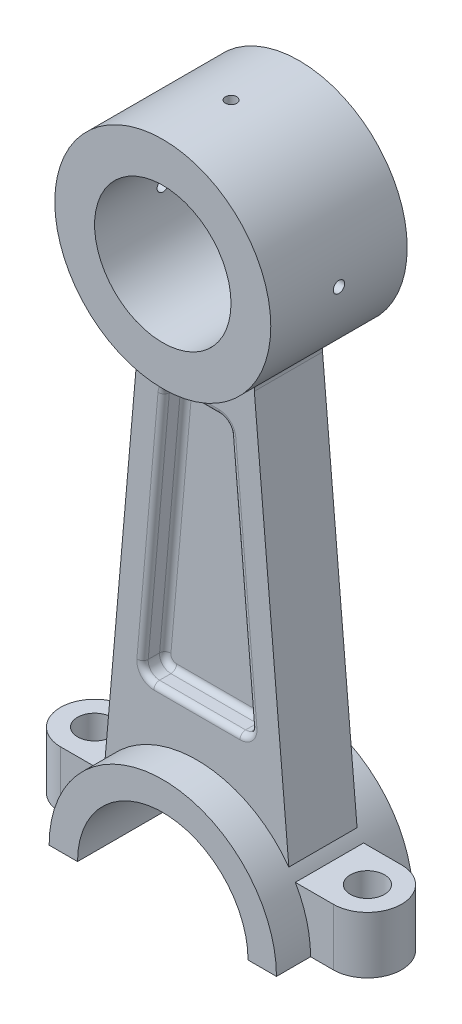
from build123d import *

# Parameters (mm, degrees)
Y_KSEKLIK_EKSTR_ZYON1_DEPTH = 12
Y_KSEKLIK_EKSTR_ZYON2_DEPTH = 6
IZIM1_4_R                   = 19
IZIM1_4_R_2                 = 12
Y_KSEKLIK_EKSTR_ZYON3_DEPTH = 12
IZIM1_5_W                   = 6
IZIM1_5_H                   = 10
Y_KSEKLIK_EKSTR_ZYON4_DEPTH = 6
KES_EKSTR_ZYON1_DEPTH       = 11
F_6_0_6_AP_DELIK1_D         = 6
KES_EKSTR_ZYON2_DEPTH       = 4
RADYUS1_R                   = 1
RADYUS2_R                   = 1
IZIM9_R                     = 1
KES_EKSTR_ZYON3_DEPTH       = 50
IZIM10_R                    = 1
KES_EKSTR_ZYON4_DEPTH       = 16
RADYUS3_R                   = 2


with BuildPart() as part:
    # Çizim1 → Yükseklik-Ekstrüzyon1 (new body, symmetric)
    with BuildSketch(Plane.XY):
        with BuildLine():
            Line((-20, 0), (-15, 0))
            ThreePointArc((-15, 0), (0, 15), (15, 0))
            Line((15, 0), (20, 0))
            ThreePointArc((20, 0), (0, 20), (-20, 0))
        make_face()
    extrude(amount=Y_KSEKLIK_EKSTR_ZYON1_DEPTH, both=True)

    # Çizim1<3> → Yükseklik-Ekstrüzyon2 (add, symmetric)
    with BuildSketch(Plane.XY):
        with BuildLine():
            Line((-10, 82.394505579), (-16.180060624, 11.756089409))
            ThreePointArc((-16.180060624, 11.756089409), (0, 20), (16.180060624, 11.756089409))
            Line((16.180060624, 11.756089409), (10, 82.394505579))
            ThreePointArc((10, 82.394505579), (0, 79.55), (-10, 82.394505579))
        make_face()
    extrude(amount=Y_KSEKLIK_EKSTR_ZYON2_DEPTH, both=True)

    # Çizim1<4> → Yükseklik-Ekstrüzyon3 (add, symmetric)
    with BuildSketch(Plane.XY):
        with Locations((0, 98.55)):
            Circle(IZIM1_4_R)
        with Locations((0, 98.55)):
            Circle(IZIM1_4_R_2, mode=Mode.SUBTRACT)
    extrude(amount=Y_KSEKLIK_EKSTR_ZYON3_DEPTH, both=True)

    # Çizim1<5> → Yükseklik-Ekstrüzyon4 (add, symmetric)
    with BuildSketch(Plane.XY):
        with Locations((-27, 5)):
            Rectangle(IZIM1_5_W, IZIM1_5_H)
        with BuildLine():
            Line((-24, 0), (-20, 0))
            ThreePointArc((-20, 0), (-19.318516526, 5.176380902), (-17.320508076, 10))
            Line((-17.320508076, 10), (-24, 10))
            Line((-24, 10), (-24, 0))
        make_face()
        with BuildLine():
            ThreePointArc((17.320508076, 10), (19.318516526, 5.176380902), (20, 0))
            Line((20, 0), (24, 0))
            Line((24, 0), (24, 10))
            Line((24, 10), (17.320508076, 10))
        make_face()
        with Locations((27, 5)):
            Rectangle(IZIM1_5_W, IZIM1_5_H)
    extrude(amount=Y_KSEKLIK_EKSTR_ZYON4_DEPTH, both=True)

    # Çizim2 → Kes-Ekstrüzyon1 (cut, through all)
    with BuildSketch(Plane(origin=(0, 10, 0), x_dir=(1, 0, 0), z_dir=(0, 1, 0))):
        with BuildLine():
            ThreePointArc((-30, 0), (-28.242640687, 4.242640687), (-24, 6))
            Line((-24, 6), (-30, 6))
            Line((-30, 6), (-30, 0))
        make_face()
        with BuildLine():
            Line((-30, -6), (-24, -6))
            ThreePointArc((-24, -6), (-28.242640687, -4.242640687), (-30, 0))
            Line((-30, 0), (-30, -6))
        make_face()
    kes_ekstr_zyon1 = extrude(amount=-KES_EKSTR_ZYON1_DEPTH, mode=Mode.SUBTRACT)

    # Ø6.0 (6) Çap Delik1 (through all)
    with Locations(Plane(origin=(0, 10, 0), x_dir=(1, 0, 0), z_dir=(0, 1, 0))):
        with Locations((-24, 0)):
            f_6_0_6_ap_delik1 = Hole(F_6_0_6_AP_DELIK1_D / 2)

    # Aynalama1: Ø6.0 (6) Çap Delik1 across plane
    add(f_6_0_6_ap_delik1.mirror(Plane(origin=(0, 0, 0), x_dir=(0, 0, 1), z_dir=(1, 0, 0))), mode=Mode.SUBTRACT)

    # Çizim8 → Kes-Ekstrüzyon2 (cut)
    with BuildSketch(Plane.XY.offset(6)):
        with BuildLine():
            Line((5.845451143, 72.512650075), (9.562487885, 30.026725708))
            ThreePointArc((9.562487885, 30.026725708), (9.044653162, 28.501233808), (7.570098489, 27.852414223))
            Line((7.570098489, 27.852414223), (-7.570098489, 27.852414223))
            ThreePointArc((-7.570098489, 27.852414223), (-9.044653162, 28.501233808), (-9.562487885, 30.026725708))
            Line((-9.562487885, 30.026725708), (-5.845451143, 72.512650075))
            ThreePointArc((-5.845451143, 72.512650075), (-5.204242163, 73.812893263), (-3.853061747, 74.338338589))
            Line((-3.853061747, 74.338338589), (3.853061747, 74.338338589))
            ThreePointArc((3.853061747, 74.338338589), (5.204242163, 73.812893263), (5.845451143, 72.512650075))
        make_face()
    kes_ekstr_zyon2 = extrude(amount=-KES_EKSTR_ZYON2_DEPTH, mode=Mode.SUBTRACT)

    # Aynalama2: Kes-Ekstrüzyon2 across plane
    add(kes_ekstr_zyon2.mirror(Plane.XY), mode=Mode.SUBTRACT)

    # Radyus1
    radyus1_edges = [part.edges().sort_by_distance(p)[0] for p in [
        (5.204242163, 73.812893263, 2),
        (7.703969514, 51.269687892, 2),
        (9.044653162, 28.501233808, 2),
        (0, 27.852414223, 2),
        (-9.044653162, 28.501233808, 2),
        (-7.703969514, 51.269687892, 2),
        (-5.204242163, 73.812893263, 2),
        (0, 74.338338589, 2),
        (5.204242163, 73.812893263, 6),
        (0, 74.338338589, 6),
        (-5.204242163, 73.812893263, 6),
        (-7.703969514, 51.269687892, 6),
        (-9.044653162, 28.501233808, 6),
        (0, 27.852414223, 6),
        (9.044653162, 28.501233808, 6),
        (7.703969514, 51.269687892, 6),
    ]]
    fillet(radyus1_edges, radius=RADYUS1_R)

    # Radyus2
    radyus2_edges = [part.edges().sort_by_distance(p)[0] for p in [
        (5.204242163, 73.812893263, -6),
        (0, 74.338338589, -6),
        (-5.204242163, 73.812893263, -6),
        (-7.703969514, 51.269687892, -6),
        (-9.044653162, 28.501233808, -6),
        (0, 27.852414223, -6),
        (9.044653162, 28.501233808, -6),
        (7.703969514, 51.269687892, -6),
        (5.204242163, 73.812893263, -2),
        (0, 74.338338589, -2),
        (-5.204242163, 73.812893263, -2),
        (-7.703969514, 51.269687892, -2),
        (-9.044653162, 28.501233808, -2),
        (0, 27.852414223, -2),
        (9.044653162, 28.501233808, -2),
        (7.703969514, 51.269687892, -2),
    ]]
    fillet(radyus2_edges, radius=RADYUS2_R)

    # Aynalama3: Kes-Ekstrüzyon1 across plane
    add(kes_ekstr_zyon1.mirror(Plane(origin=(0, 0, 0), x_dir=(0, 0, 1), z_dir=(1, 0, 0))), mode=Mode.SUBTRACT)

    # Çizim9 → Kes-Ekstrüzyon3 (cut, through all)
    with BuildSketch(Plane(origin=(19, 0, 0), x_dir=(0, 0, -1), z_dir=(1, 0, 0))):
        with Locations((0, 98.55)):
            Circle(IZIM9_R)
    extrude(amount=-KES_EKSTR_ZYON3_DEPTH, mode=Mode.SUBTRACT)

    # Çizim10 → Kes-Ekstrüzyon4 (cut)
    with BuildSketch(Plane(origin=(0, 117.55, 0), x_dir=(1, 0, 0), z_dir=(0, 1, 0))):
        Circle(IZIM10_R)
    extrude(amount=-KES_EKSTR_ZYON4_DEPTH, mode=Mode.SUBTRACT)

    # Radyus3
    radyus3_edges = [part.edges().sort_by_distance(p)[0] for p in [
        (10, 82.394505579, 0),
        (-10, 82.394505579, 0),
    ]]
    fillet(radyus3_edges, radius=RADYUS3_R)


solid = part.part
